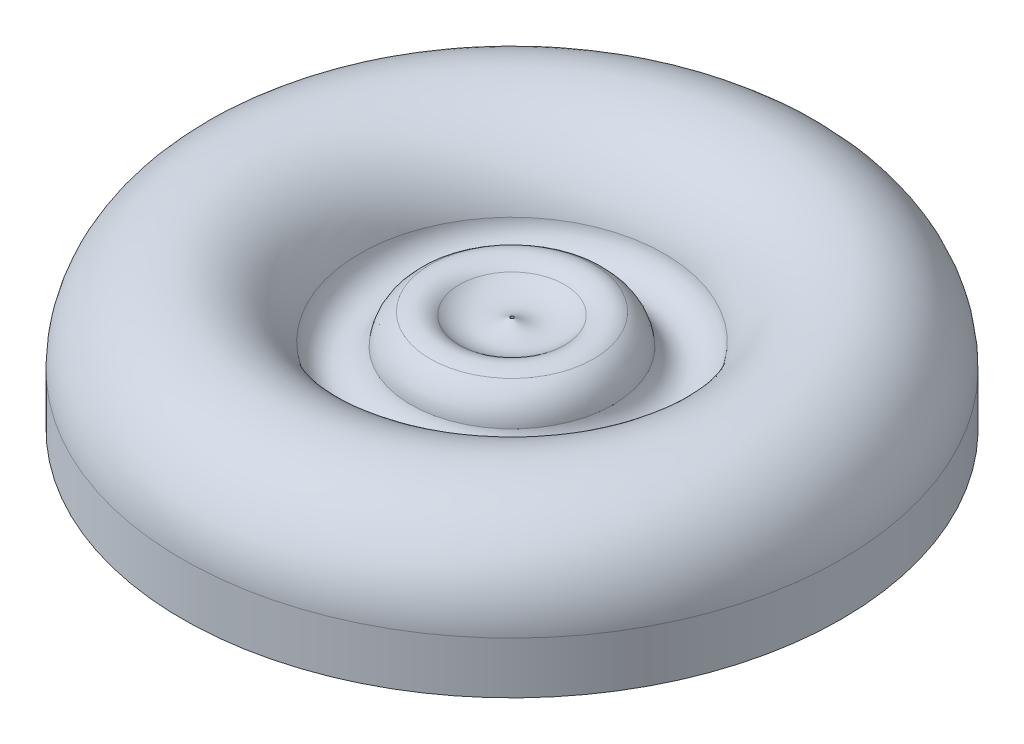
from build123d import *


with BuildPart() as part:
    # Sketch2 → Revolve15 (revolve)
    with BuildSketch(Plane.XY):
        with BuildLine():
            ThreePointArc((-11.057536139, 6.861664444), (-8.978939648, 7.301650711), (-7.020479446, 6.477888049))
            ThreePointArc((-7.020479446, 6.477888049), (-3.561535652, 5.127833284), (0, 6.177787489))
            Line((0, 6.177787489), (0, -7.137400499))
            Line((0, -7.137400499), (-45.237397251, -7.137400499))
            Line((-45.237397251, -7.137400499), (-45.237397251, -4.99e-07))
            ThreePointArc((-45.237397251, -4.99e-07), (-34.450523736, 12.334918038), (-20.787740284, 3.288636819))
            ThreePointArc((-20.787740284, 3.288636819), (-17.488645172, 0.175380579), (-13.722322326, 2.703463882))
            ThreePointArc((-13.722322326, 2.703463882), (-12.908547636, 5.114921185), (-11.057536139, 6.861664444))
        make_face()
    revolve(axis=Axis((0.228383109, -0.616910329, 0), (0, 1, 0)))


solid = part.part
